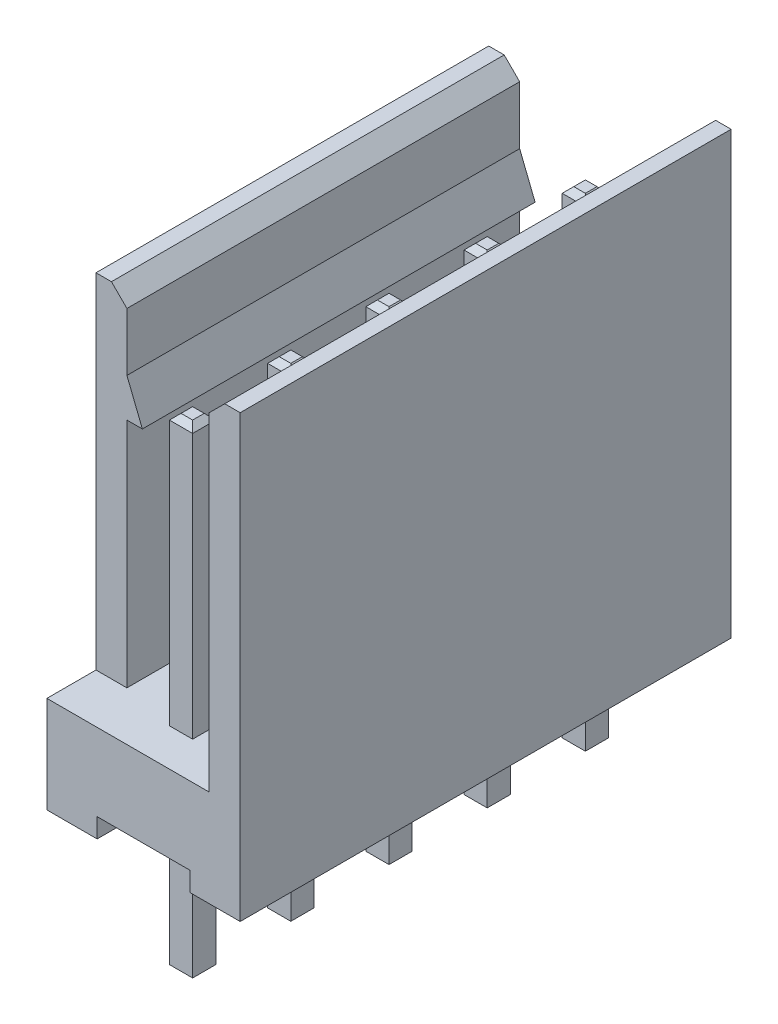
from build123d import *

# Parameters (mm, degrees)
BOSS_EXTRU_1_DEPTH      = 12.7
ESQUISSE3_W             = 0.8
ESQUISSE3_H             = 1.27
ENL_V_MAT_EXTRU_1_DEPTH = 8.9
ESQUISSE4_W             = 2.4
ESQUISSE4_H             = 0.5
ENL_V_MAT_EXTRU_2_DEPTH = 13.7
ESQUISSE2_W             = 0.6
ESQUISSE2_H             = 0.6
BOSS_EXTRU_2_DEPTH      = 3.5
BOSS_EXTRU_2_DEPTH_BACK = 9
BOSS_EXTRU_3_DEPTH      = 10.16
CHANFREIN4_SIZE         = 0.15
CHANFREIN5_SIZE         = 0.4


with BuildPart() as part:
    # Esquisse1 → Boss.-Extru.1 (new body)
    with BuildSketch(Plane.XY):
        Polygon((0, 11.4), (0, 0), (5, 0), (5, 11.4), (4.2, 11.4), (4.2, 2.5), (0.8, 2.5), (0.8, 11.4), align=None)
    extrude(amount=BOSS_EXTRU_1_DEPTH)

    # Esquisse3 → Enlèv. mat.-Extru.1 (cut)
    with BuildSketch(Plane(origin=(0, 11.4, 0), x_dir=(1, 0, 0), z_dir=(0, 1, 0))):
        with Locations((0.4, -0.635)):
            Rectangle(ESQUISSE3_W, ESQUISSE3_H)
        with Locations((0.4, -12.065)):
            Rectangle(ESQUISSE3_W, ESQUISSE3_H)
    extrude(amount=-ENL_V_MAT_EXTRU_1_DEPTH, mode=Mode.SUBTRACT)

    # Esquisse4 → Enlèv. mat.-Extru.2 (cut, through all)
    with BuildSketch(Plane.XY.offset(12.7)):
        with Locations((2.5, 0.25)):
            Rectangle(ESQUISSE4_W, ESQUISSE4_H)
    extrude(amount=-ENL_V_MAT_EXTRU_2_DEPTH, mode=Mode.SUBTRACT)

    # Esquisse2 → Boss.-Extru.2 (add, two sides)
    with BuildSketch(Plane.XZ.offset(-0.5)) as boss_extru_2_sk:
        with Locations((2.5, 11.43)):
            Rectangle(ESQUISSE2_W, ESQUISSE2_H)
        with Locations((2.5, 1.27)):
            Rectangle(ESQUISSE2_W, ESQUISSE2_H)
        with Locations((2.5, 8.89)):
            Rectangle(ESQUISSE2_W, ESQUISSE2_H)
        with Locations((2.5, 6.35)):
            Rectangle(ESQUISSE2_W, ESQUISSE2_H)
        with Locations((2.5, 3.81)):
            Rectangle(ESQUISSE2_W, ESQUISSE2_H)
    extrude(amount=BOSS_EXTRU_2_DEPTH)
    extrude(boss_extru_2_sk.sketch, amount=-BOSS_EXTRU_2_DEPTH_BACK)

    # Esquisse5 → Boss.-Extru.3 (add)
    with BuildSketch(Plane.XY.offset(11.43)):
        Polygon((0.8, 9.5), (1.2, 8.5), (0.8, 8.5), align=None)
    extrude(amount=-BOSS_EXTRU_3_DEPTH)

    # Chanfrein4
    chanfrein4_edges = [part.edges().sort_by_distance(p)[0] for p in [
        (2.8, 9.5, 8.89),
        (2.5, 9.5, 8.59),
        (2.2, 9.5, 8.89),
        (2.5, 9.5, 9.19),
        (2.8, -3, 8.89),
        (2.5, -3, 9.19),
        (2.2, -3, 8.89),
        (2.5, -3, 8.59),
        (2.8, 9.5, 6.35),
        (2.5, 9.5, 6.05),
        (2.2, 9.5, 6.35),
        (2.5, 9.5, 6.65),
        (2.8, -3, 6.35),
        (2.5, -3, 6.65),
        (2.2, -3, 6.35),
        (2.5, -3, 6.05),
        (2.8, 9.5, 3.81),
        (2.5, 9.5, 3.51),
        (2.2, 9.5, 3.81),
        (2.5, 9.5, 4.11),
        (2.8, -3, 3.81),
        (2.5, -3, 4.11),
        (2.2, -3, 3.81),
        (2.5, -3, 3.51),
        (2.8, 9.5, 11.43),
        (2.5, 9.5, 11.13),
        (2.2, 9.5, 11.43),
        (2.5, 9.5, 11.73),
        (2.8, -3, 11.43),
        (2.5, -3, 11.73),
        (2.2, -3, 11.43),
        (2.5, -3, 11.13),
        (2.8, 9.5, 1.27),
        (2.5, 9.5, 0.97),
        (2.2, 9.5, 1.27),
        (2.5, 9.5, 1.57),
        (2.8, -3, 1.27),
        (2.5, -3, 1.57),
        (2.2, -3, 1.27),
        (2.5, -3, 0.97),
    ]]
    chamfer(chanfrein4_edges, length=CHANFREIN4_SIZE)

    # Chanfrein5
    chanfrein5_edges = [part.edges().sort_by_distance(p)[0] for p in [
        (4.2, 11.4, 6.35),
        (0.8, 11.4, 6.35),
    ]]
    chamfer(chanfrein5_edges, length=CHANFREIN5_SIZE)


solid = part.part
